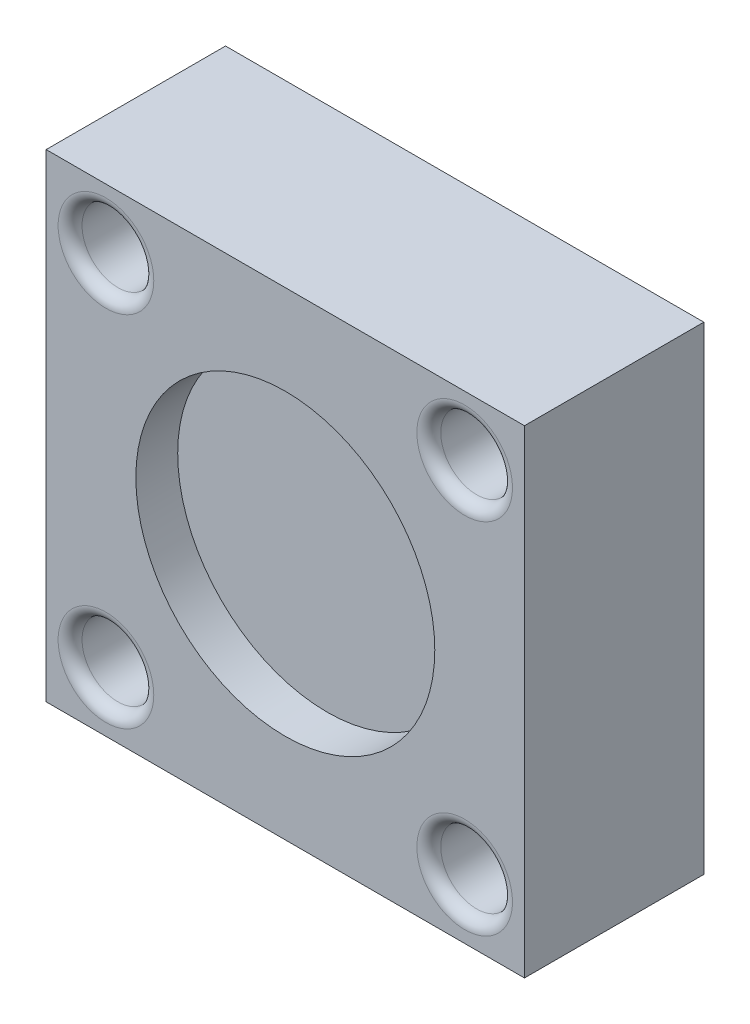
from build123d import *

# Parameters (mm, degrees)
SKETCH1_W           = 40
SKETCH1_H           = 40
BOSS_EXTRUDE1_DEPTH = 15
SKETCH3_R           = 1.75
CUT_EXTRUDE2_DEPTH  = 16
SKETCH4_R           = 3
CUT_EXTRUDE3_DEPTH  = 7
FILLET1_R           = 1
SKETCH5_R           = 12.5
CUT_EXTRUDE4_DEPTH  = 3.5


with BuildPart() as part:
    # Sketch1 → Boss-Extrude1 (new body)
    with BuildSketch(Plane.XY):
        Rectangle(SKETCH1_W, SKETCH1_H)
    extrude(amount=BOSS_EXTRUDE1_DEPTH)

    # Sketch3 → Cut-Extrude2 (cut, through all)
    with BuildSketch(Plane.XY.offset(15)):
        with Locations((15, 15)):
            Circle(SKETCH3_R)
        with Locations((15, -15)):
            Circle(SKETCH3_R)
        with Locations((-15, 15)):
            Circle(SKETCH3_R)
        with Locations((-15, -15)):
            Circle(SKETCH3_R)
    extrude(amount=-CUT_EXTRUDE2_DEPTH, mode=Mode.SUBTRACT)

    # Sketch4 → Cut-Extrude3 (cut)
    with BuildSketch(Plane.XY.offset(15)):
        with Locations((15, 15)):
            Circle(SKETCH4_R)
        with Locations((15, -15)):
            Circle(SKETCH4_R)
        with Locations((-15, -15)):
            Circle(SKETCH4_R)
        with Locations((-15, 15)):
            Circle(SKETCH4_R)
    extrude(amount=-CUT_EXTRUDE3_DEPTH, mode=Mode.SUBTRACT)

    # Fillet1
    fillet1_edges = [part.edges().sort_by_distance(p)[0] for p in [
        (12, 15, 15),
        (12, -15, 15),
        (-18, -15, 15),
        (-18, 15, 15),
    ]]
    fillet(fillet1_edges, radius=FILLET1_R)

    # Sketch5 → Cut-Extrude4 (cut)
    with BuildSketch(Plane.XY.offset(15)):
        Circle(SKETCH5_R)
    extrude(amount=-CUT_EXTRUDE4_DEPTH, mode=Mode.SUBTRACT)


solid = part.part
